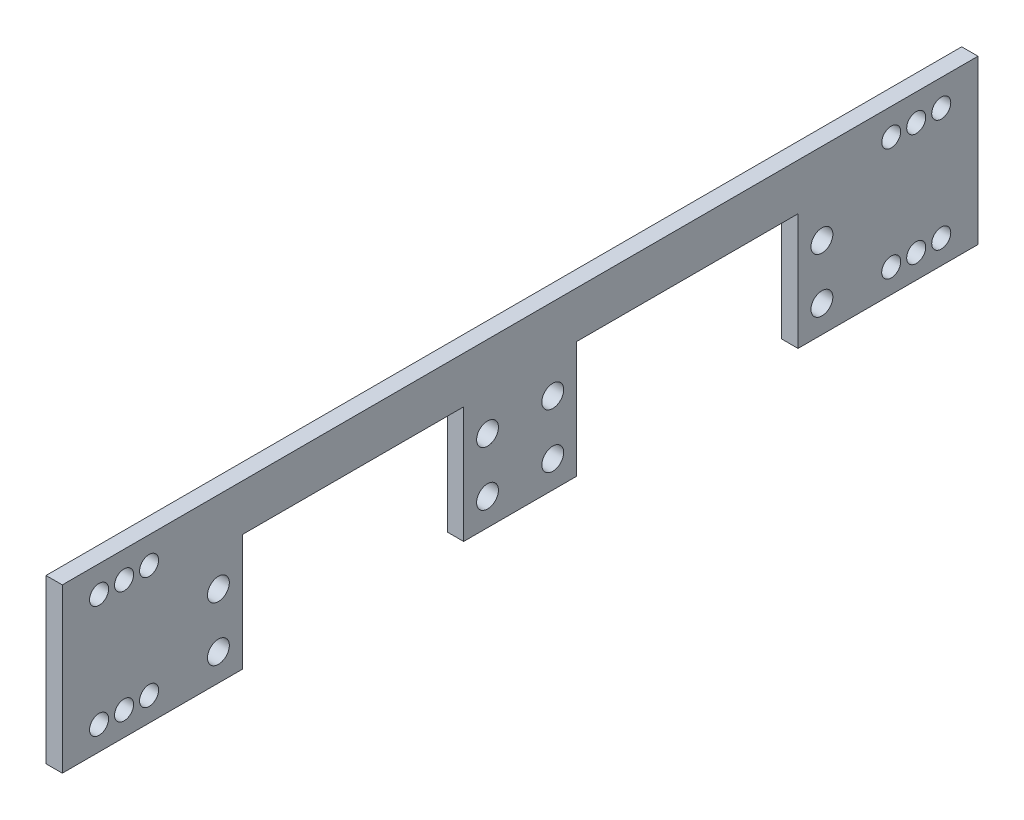
from build123d import *

# Parameters (mm, degrees)
SKETCH1_R           = 2.01
SKETCH1_R_2         = 1.75
BOSS_EXTRUDE1_DEPTH = 3
BOSS_EXTRUDE2_DEPTH = 3


with BuildPart() as part:
    # Sketch1 → Boss-Extrude1 (new body)
    with BuildSketch(Plane(origin=(0, 0, 0), x_dir=(0, 0, -1), z_dir=(1, 0, 0))):
        Polygon((51.106463596, 21.456503046), (51.106463596, 0), (84.21, 0), (84.21, 30), (-84.21, 30), (-84.21, 0), (-51.106463596, 0), (-51.106463596, 21.456503046), (-10.393536404, 21.456503046), (-10.393536404, 0), (10.393536404, 0), (10.393536404, 21.456503046), align=None)
        with Locations((55.5, 15)):
            Circle(SKETCH1_R, mode=Mode.SUBTRACT)
        with Locations((55.5, 5)):
            Circle(SKETCH1_R, mode=Mode.SUBTRACT)
        with Locations((-77.45, 4.408333333)):
            Circle(SKETCH1_R_2, mode=Mode.SUBTRACT)
        with Locations((-72.85, 4.408333333)):
            Circle(SKETCH1_R_2, mode=Mode.SUBTRACT)
        with Locations((-68.25, 4.408333333)):
            Circle(SKETCH1_R_2, mode=Mode.SUBTRACT)
        with Locations((-55.5, 5)):
            Circle(SKETCH1_R, mode=Mode.SUBTRACT)
        with Locations((-6, 5)):
            Circle(SKETCH1_R, mode=Mode.SUBTRACT)
        with Locations((6, 5)):
            Circle(SKETCH1_R, mode=Mode.SUBTRACT)
        with Locations((68.25, 4.408333333)):
            Circle(SKETCH1_R_2, mode=Mode.SUBTRACT)
        with Locations((-55.5, 15)):
            Circle(SKETCH1_R, mode=Mode.SUBTRACT)
        with Locations((-6, 15)):
            Circle(SKETCH1_R, mode=Mode.SUBTRACT)
        with Locations((-77.45, 25.111666667)):
            Circle(SKETCH1_R_2, mode=Mode.SUBTRACT)
        with Locations((-72.85, 25.111666667)):
            Circle(SKETCH1_R_2, mode=Mode.SUBTRACT)
        with Locations((-68.25, 25.111666667)):
            Circle(SKETCH1_R_2, mode=Mode.SUBTRACT)
        with Locations((6, 15)):
            Circle(SKETCH1_R, mode=Mode.SUBTRACT)
        with Locations((77.45, 25.111666667)):
            Circle(SKETCH1_R_2, mode=Mode.SUBTRACT)
        with Locations((77.45, 4.408333333)):
            Circle(SKETCH1_R_2, mode=Mode.SUBTRACT)
        with Locations((72.85, 4.408333333)):
            Circle(SKETCH1_R_2, mode=Mode.SUBTRACT)
        with Locations((72.85, 25.111666667)):
            Circle(SKETCH1_R_2, mode=Mode.SUBTRACT)
        with BuildLine():
            Line((68.25, 23.119646681), (66.786206896, 22.802700472))
            Line((66.786206896, 22.802700472), (67.318515469, 23.642356362))
            ThreePointArc((67.318515469, 23.642356362), (68.734966733, 26.782398085), (68.25, 23.371972382))
            Line((68.25, 23.371972382), (68.25, 23.119646681))
        make_face(mode=Mode.SUBTRACT)
    extrude(amount=BOSS_EXTRUDE1_DEPTH)

    # Sketch2 → Boss-Extrude2 (add)
    with BuildSketch(Plane.ZY):
        with BuildLine():
            Line((-68.25, 23.371972382), (-68.25, 23.119646681))
            Line((-68.25, 23.119646681), (-66.825746374, 22.811261715))
            Line((-66.825746374, 22.811261715), (-66.786206896, 22.802700472))
            Line((-66.786206896, 22.802700472), (-67.318515469, 23.642356362))
            ThreePointArc((-67.318515469, 23.642356362), (-67.765033267, 23.440935248), (-68.25, 23.371972382))
        make_face()
    extrude(amount=-BOSS_EXTRUDE2_DEPTH)


solid = part.part
